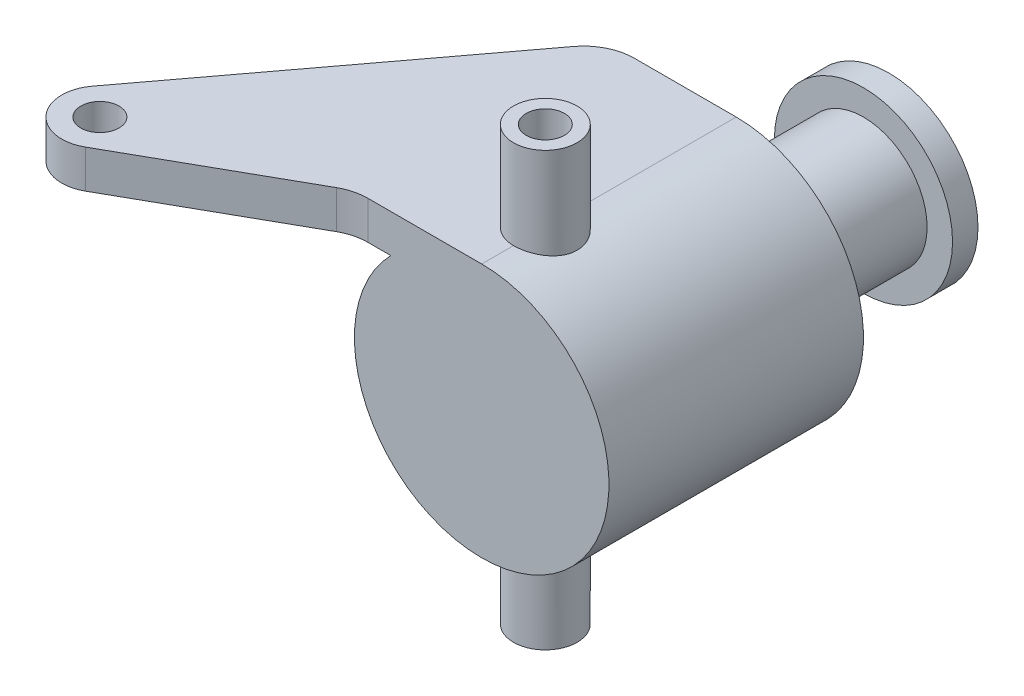
from build123d import *

# Parameters (mm, degrees)
SKETCH1_R               = 12.7
BOSS_EXTRUDE1_DEPTH     = 12.7
SKETCH2_R               = 1.905
BOSS_EXTRUDE2_DEPTH     = 3.81
SKETCH3_R               = 6.35
BOSS_EXTRUDE3_DEPTH     = 12.7
SKETCH4_R               = 8.89
BOSS_EXTRUDE4_DEPTH     = 2.54
SKETCH5_R               = 3.175
BOSS_EXTRUDE5_DEPTH     = 21.59
SKETCH6_R               = 1.905
CUT_EXTRUDE1_DEPTH      = 22.5900001
CUT_EXTRUDE1_DEPTH_BACK = 22.5900001


with BuildPart() as part:
    # Sketch1 → Boss-Extrude1 (new body, symmetric)
    with BuildSketch(Plane.XY):
        Circle(SKETCH1_R)
    extrude(amount=BOSS_EXTRUDE1_DEPTH, both=True)

    # Sketch2 → Boss-Extrude2 (add)
    with BuildSketch(Plane(origin=(0, 12.7, 0), x_dir=(1, 0, 0), z_dir=(0, 1, 0))):
        with BuildLine():
            Line((0, 12.7), (0, -12.7))
            Line((0, -12.7), (-11.368596271, -12.7))
            ThreePointArc((-11.368596271, -12.7), (-12.656501603, -12.865969083), (-13.860252421, -13.353031553))
            Line((-13.860252421, -13.353031553), (-29.881257888, -22.370226336))
            ThreePointArc((-29.881257888, -22.370226336), (-34.614455572, -21.562169237), (-34.798, -16.764))
            Line((-34.798, -16.764), (-14.224, 10.668))
            ThreePointArc((-14.224, 10.668), (-12.431845065, 12.16369013), (-10.16, 12.7))
            Line((-10.16, 12.7), (0, 12.7))
        make_face()
        with Locations((-31.75, -19.05)):
            Circle(SKETCH2_R, mode=Mode.SUBTRACT)
    extrude(amount=-BOSS_EXTRUDE2_DEPTH)

    # Sketch3 → Boss-Extrude3 (add)
    with BuildSketch(Plane(origin=(0, 0, -12.7), x_dir=(-1, 0, 0), z_dir=(0, 0, -1))):
        Circle(SKETCH3_R)
    extrude(amount=BOSS_EXTRUDE3_DEPTH)

    # Sketch4 → Boss-Extrude4 (add)
    with BuildSketch(Plane(origin=(0, 0, -25.4), x_dir=(-1, 0, 0), z_dir=(0, 0, -1))):
        Circle(SKETCH4_R)
    extrude(amount=BOSS_EXTRUDE4_DEPTH)

    # Sketch5 → Boss-Extrude5 (add, symmetric)
    with BuildSketch(Plane(origin=(0, 0, 0), x_dir=(1, 0, 0), z_dir=(0, 1, 0))):
        with Locations((0, -6.35)):
            Circle(SKETCH5_R)
    extrude(amount=BOSS_EXTRUDE5_DEPTH, both=True)

    # Sketch6 → Cut-Extrude1 (cut, two sides)
    with BuildSketch(Plane(origin=(0, 0, 0), x_dir=(1, 0, 0), z_dir=(0, 1, 0))) as cut_extrude1_sk:
        with Locations((0, -6.35)):
            Circle(SKETCH6_R)
    extrude(amount=CUT_EXTRUDE1_DEPTH, mode=Mode.SUBTRACT)
    extrude(cut_extrude1_sk.sketch, amount=-CUT_EXTRUDE1_DEPTH_BACK, mode=Mode.SUBTRACT)


solid = part.part
